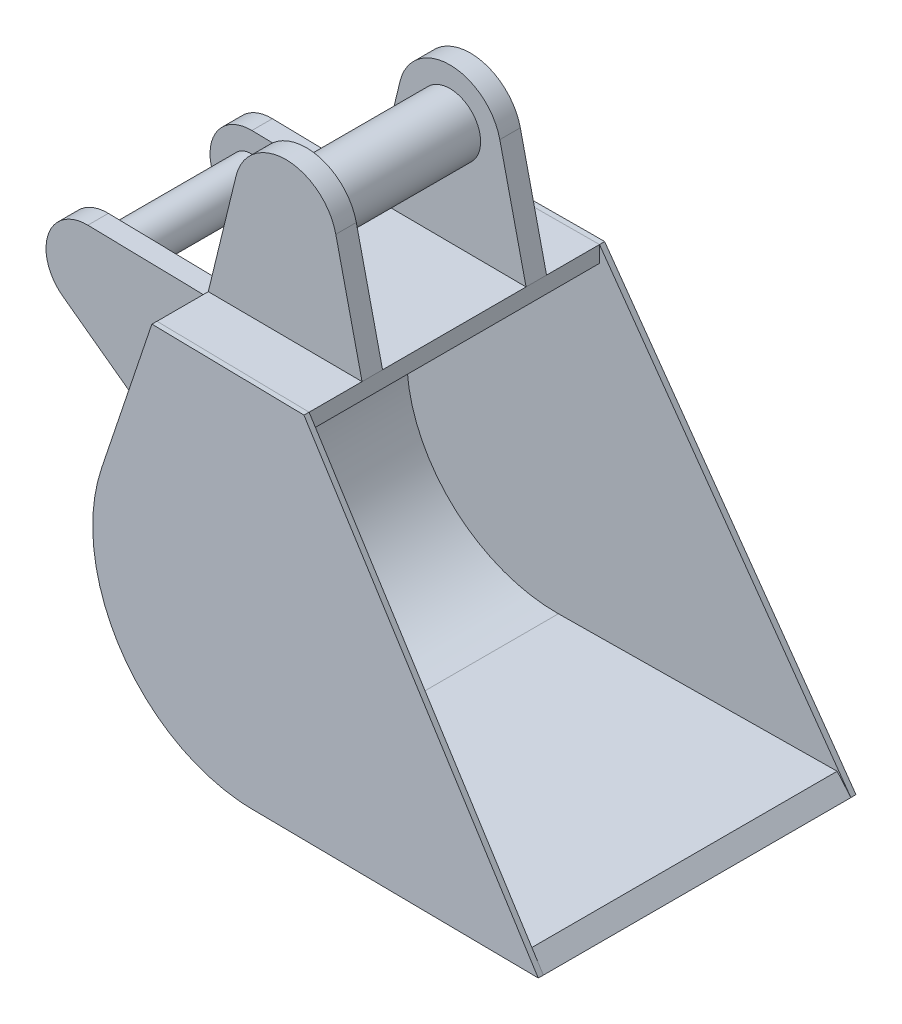
from build123d import *

# Parameters (mm, degrees)
BOSS_EXTRUDE1_DEPTH = 150
CUT_EXTRUDE1_DEPTH  = 368.015632897
BOSS_EXTRUDE3_DEPTH = 5
BOSS_EXTRUDE4_START = 70
BOSS_EXTRUDE4_DEPTH = 20
SKETCH6_R           = 30
SKETCH6_R_2         = 20
BOSS_EXTRUDE5_DEPTH = 90


with BuildPart() as part:
    # Sketch1 → Boss-Extrude1 (new body, symmetric)
    with BuildSketch(Plane.XY):
        with BuildLine():
            Line((0, 0), (-269.007095808, 0))
            ThreePointArc((-269.007095808, 0), (-385.585141332, 59.468589851), (-405.875242761, 188.756120808))
            Line((-405.875242761, 188.756120808), (-362.32962564, 321.922441203))
            Line((-362.32962564, 321.922441203), (-224.01265789, 321))
            Line((-224.01265789, 321), (-223.905955644, 336.999644203))
            Line((-223.905955644, 336.999644203), (-373.905955644, 338))
            Line((-373.905955644, 338), (-421.082814644, 193.72902312))
            ThreePointArc((-421.082814644, 193.72902312), (-398.538257501, 50.076210945), (-269.007095808, -16))
            Line((-269.007095808, -16), (13, -16))
            Line((13, -16), (0, 0))
        make_face()
    extrude(amount=BOSS_EXTRUDE1_DEPTH, both=True)

    # Sketch2 → Cut-Extrude1 (cut, through all)
    with BuildSketch(Plane(origin=(1.559593234, 1.046677898, 0), x_dir=(0, 0, -1), z_dir=(0.83033878, 0.557258925, 0))):
        Polygon((-150, -20.529786514), (-140, 489.016938742), (-150, 489.016938742), align=None)
        Polygon((140, 489.016938742), (150, 489.016938742), (150, -20.529786514), align=None)
    extrude(amount=-CUT_EXTRUDE1_DEPTH, mode=Mode.SUBTRACT)

    # Sketch4 → Boss-Extrude3 (add)
    with BuildSketch(Plane(origin=(-1.635418654, 2.436841241, 149.539501663), x_dir=(0.999940218, 0.000134312, 0.010933523), z_dir=(-0.01093426, 0.016292498, 0.99980748))):
        with BuildLine():
            Line((14.637102301, -18.441255084), (-267.38685506, -18.403370819))
            add(Edge.make_bspline(
                [(-419.48086469, 191.373926331), (-488.057520629, -18.373728139), (-267.38685506, -18.403370819)],
                knots=[0.663674022, 0.663674022, 0.663674022, 2.550511677, 2.550511677, 2.550511677], degree=2, weights=[1, 0.587023682, 1]))
            Line((-419.48086469, 191.373926331), (-372.30751216, 335.657719572))
            Line((-372.30751216, 335.657719572), (-222.298499603, 334.637080266))
            Line((-222.298499603, 334.637080266), (14.637102301, -18.441255084))
        make_face()
    boss_extrude3 = extrude(amount=BOSS_EXTRUDE3_DEPTH)

    # Sketch5 → Boss-Extrude4 (add)
    with BuildSketch(Plane.XY.offset(BOSS_EXTRUDE4_START)):
        with BuildLine():
            Line((-373.905955644, 338), (-223.905955644, 336.999644203))
            Line((-223.905955644, 336.999644203), (-249.503039478, 448.668975164))
            ThreePointArc((-249.503039478, 448.668975164), (-297.905622093, 487.496486507), (-346.8217607, 449.317997476))
            Line((-346.8217607, 449.317997476), (-373.905955644, 338))
        make_face()
        with BuildLine():
            Line((-421.082814644, 193.72902312), (-515.85308915, 263.184838763))
            ThreePointArc((-515.85308915, 263.184838763), (-530.093343715, 308.281281099), (-491.377505751, 335.439297452))
            Line((-491.377505751, 335.439297452), (-373.905955644, 333))
            Line((-373.905955644, 333), (-421.082814644, 193.72902312))
        make_face()
    boss_extrude4 = extrude(amount=BOSS_EXTRUDE4_DEPTH)

    # Mirror4: Boss-Extrude3, Boss-Extrude4 across plane
    add(boss_extrude3.mirror(Plane.XY))
    add(boss_extrude4.mirror(Plane.XY))

    # Sketch6 → Boss-Extrude5 (add, symmetric)
    with BuildSketch(Plane.XY):
        with Locations((-298.23906661, 437.497598372)):
            Circle(SKETCH6_R)
        with Locations((-492.207926981, 295.447918374)):
            Circle(SKETCH6_R_2)
    extrude(amount=BOSS_EXTRUDE5_DEPTH, both=True)


solid = part.part
